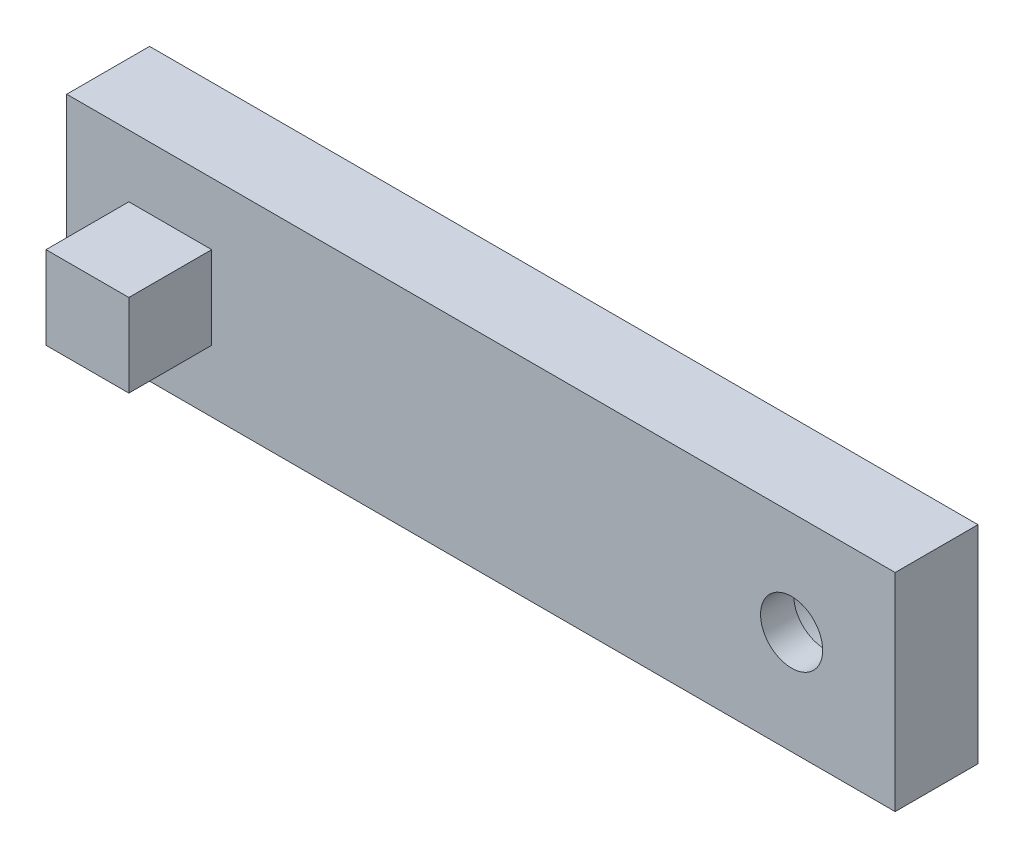
from build123d import *

# Parameters (mm, degrees)
ESQUISSE1_W             = 200
ESQUISSE1_H             = 50
BOSS_EXTRU_1_DEPTH      = 20
ESQUISSE2_W             = 20
ESQUISSE2_H             = 20
BOSS_EXTRU_2_DEPTH      = 20
ESQUISSE3_R             = 7.5
ENL_V_MAT_EXTRU_1_DEPTH = 20
ESQUISSE8_R             = 16.25
ENL_V_MAT_EXTRU_3_DEPTH = 12


with BuildPart() as part:
    # Esquisse1 → Boss.-Extru.1 (new body)
    with BuildSketch(Plane.XY):
        Rectangle(ESQUISSE1_W, ESQUISSE1_H)
    extrude(amount=BOSS_EXTRU_1_DEPTH)

    # Esquisse2 → Boss.-Extru.2 (add)
    with BuildSketch(Plane.XY.offset(20)):
        with Locations((-75, 0)):
            Rectangle(ESQUISSE2_W, ESQUISSE2_H)
    extrude(amount=BOSS_EXTRU_2_DEPTH)

    # Esquisse3 → Enlèv. mat.-Extru.1 (cut)
    with BuildSketch(Plane.XY.offset(20)):
        with Locations((75, 0)):
            Circle(ESQUISSE3_R)
    extrude(amount=-ENL_V_MAT_EXTRU_1_DEPTH, mode=Mode.SUBTRACT)

    # Esquisse8 → Enlèv. mat.-Extru.3 (cut)
    with BuildSketch(Plane(origin=(0, 0, 0), x_dir=(-1, 0, 0), z_dir=(0, 0, -1))):
        with Locations((-75, 0)):
            Circle(ESQUISSE8_R)
    extrude(amount=-ENL_V_MAT_EXTRU_3_DEPTH, mode=Mode.SUBTRACT)


solid = part.part
